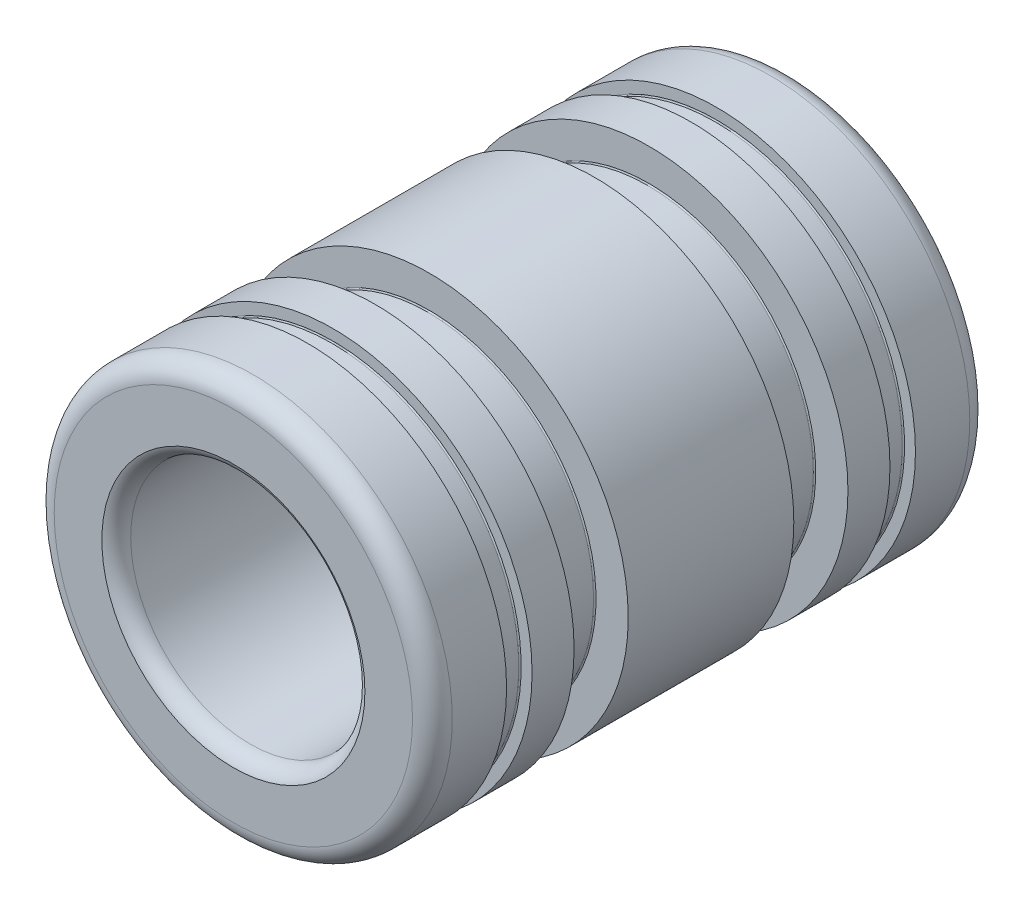
from build123d import *

# Parameters (mm, degrees)
FILLET1_R = 0.7921625
FILLET2_R = 0.04826


with BuildPart() as part:
    # Sketch3 → Revolve1 (revolve)
    with BuildSketch(Plane(origin=(0, 0, 0), x_dir=(0, 0, -1), z_dir=(1, 0, 0))):
        Polygon((-11.1125, 7.9375), (-8.1534, 7.9375), (-8.1534, 7.4549), (-7.1374, 7.4549), (-7.1374, 7.9375), (-5.461, 7.9375), (-5.461, 6.604), (-3.302, 6.604), (-3.302, 7.9375), (3.302, 7.9375), (3.302, 6.604), (5.461, 6.604), (5.461, 7.9375), (7.1374, 7.9375), (7.1374, 7.4549), (8.1534, 7.4549), (8.1534, 7.9375), (11.1125, 7.9375), (11.1125, 5.245735), (-11.1125, 5.245735), align=None)
    revolve(axis=Axis((0, 0, 11.1125), (0, 0, -1)))

    # Fillet1
    fillet1_edges = [part.edges().sort_by_distance(p)[0] for p in [
        (0, -7.9375, 11.1125),
        (0, -7.9375, -11.1125),
    ]]
    fillet(fillet1_edges, radius=FILLET1_R)

    # Fillet2
    fillet2_edges = [part.edges().sort_by_distance(p)[0] for p in [
        (0, -7.4549, 8.1534),
        (0, -7.4549, 7.1374),
        (0, -6.604, 5.461),
        (0, -6.604, 3.302),
        (0, -6.604, -3.302),
        (0, -6.604, -5.461),
        (0, -7.4549, -7.1374),
        (0, -7.4549, -8.1534),
    ]]
    fillet(fillet2_edges, radius=FILLET2_R)


with BuildPart() as body_2:
    # Sketch4 → Revolve2 (revolve)
    with BuildSketch(Plane(origin=(0, 0, 0), x_dir=(0, 0, -1), z_dir=(1, 0, 0))):
        with BuildLine():
            Line((10.438082765, 4.76885), (-10.438082765, 4.76885))
            ThreePointArc((-10.438082765, 4.76885), (-10.85107729, 4.900115042), (-11.1125, 5.245735))
            Line((-11.1125, 5.245735), (0, 5.245735))
            Line((0, 5.245735), (11.1125, 5.245735))
            ThreePointArc((11.1125, 5.245735), (10.85107729, 4.900115042), (10.438082765, 4.76885))
        make_face()
    revolve(axis=Axis((0, 0, 11.1125), (0, 0, -1)))


solid = Compound([part.part, body_2.part])
